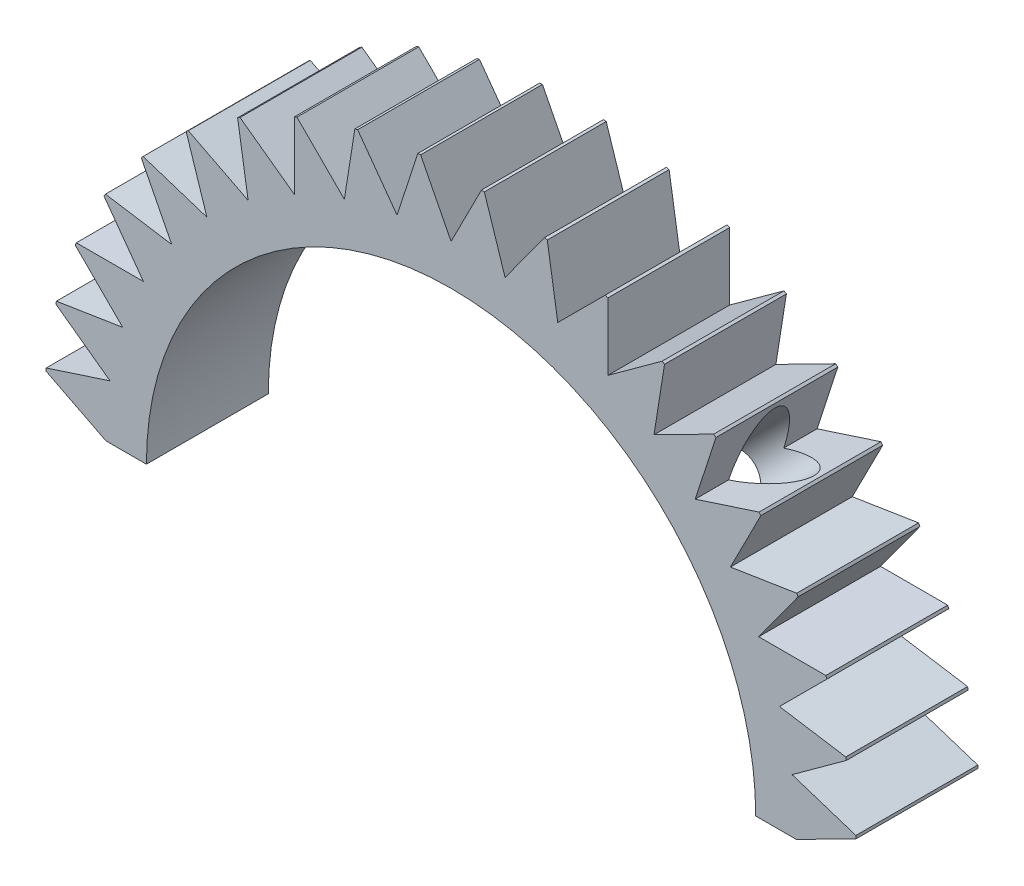
from build123d import *

# Parameters (mm, degrees)
BOSS_EXTRUDE1_DEPTH    = 7.5
CUT_EXTRUDE1_DEPTH     = 7.5
M8X1_25_TAPPED_HOLE4_D = 6.8
M8X1_25_TAPPED_HOLE5_D = 6.8


with BuildPart() as part:
    # Sketch1 → Boss-Extrude1 (new body, symmetric)
    with BuildSketch(Plane.XY):
        with BuildLine():
            Line((-50, 0), (-37.5, 0))
            ThreePointArc((-37.5, 0), (0, 37.5), (37.5, 0))
            Line((37.5, 0), (50, 0))
            ThreePointArc((50, 0), (0, 50), (-50, 0))
        make_face()
    extrude(amount=BOSS_EXTRUDE1_DEPTH, both=True)

    # Sketch2 → Cut-Extrude1 (cut, symmetric)
    with BuildSketch(Plane.XY):
        with BuildLine():
            Line((-3.75, 49.859176688), (0, 42.5))
            Line((0, 42.5), (3.75, 49.859176688))
            ThreePointArc((3.75, 49.859176688), (0, 50), (-3.75, 49.859176688))
        make_face()
        with BuildLine():
            Line((4.095862355, 49.83195673), (6.648464764, 41.976754475))
            Line((6.648464764, 41.976754475), (11.50352491, 48.658698242))
            ThreePointArc((11.50352491, 48.658698242), (7.821723252, 49.38441703), (4.095862355, 49.83195673))
        make_face()
        with BuildLine():
            Line((11.840870986, 48.577708615), (13.133222261, 40.419901943))
            Line((13.133222261, 40.419901943), (18.973794858, 46.260081157))
            ThreePointArc((18.973794858, 46.260081157), (15.450849719, 47.552825815), (11.840870986, 48.577708615))
        make_face()
        with BuildLine():
            Line((19.294318075, 46.127316094), (19.294596239, 37.867777278))
            Line((19.294596239, 37.867777278), (25.976867007, 42.722387346))
            ThreePointArc((25.976867007, 42.722387346), (22.699524987, 44.550326209), (19.294318075, 46.127316094))
        make_face()
        with BuildLine():
            Line((26.27267502, 42.541115962), (24.980873222, 34.383222261))
            Line((24.980873222, 34.383222261), (32.340302478, 38.13272657))
            ThreePointArc((32.340302478, 38.13272657), (29.389262615, 40.450849719), (26.27267502, 42.541115962))
        make_face()
        with BuildLine():
            Line((32.604111511, 37.90741237), (30.0520382, 30.0520382))
            Line((30.0520382, 30.0520382), (37.90741237, 32.604111511))
            ThreePointArc((37.90741237, 32.604111511), (35.355339059, 35.355339059), (32.604111511, 37.90741237))
        make_face()
        with BuildLine():
            Line((38.13272657, 32.340302478), (34.383222261, 24.980873222))
            Line((34.383222261, 24.980873222), (42.541115962, 26.27267502))
            ThreePointArc((42.541115962, 26.27267502), (40.450849719, 29.389262615), (38.13272657, 32.340302478))
        make_face()
        with BuildLine():
            Line((42.722387346, 25.976867007), (37.867777278, 19.294596239))
            Line((37.867777278, 19.294596239), (46.127316094, 19.294318075))
            ThreePointArc((46.127316094, 19.294318075), (44.550326209, 22.699524987), (42.722387346, 25.976867007))
        make_face()
        with BuildLine():
            Line((46.260081157, 18.973794858), (40.419901943, 13.133222261))
            Line((40.419901943, 13.133222261), (48.577708615, 11.840870986))
            ThreePointArc((48.577708615, 11.840870986), (47.552825815, 15.450849719), (46.260081157, 18.973794858))
        make_face()
        with BuildLine():
            Line((48.658698242, 11.50352491), (41.976754475, 6.648464764))
            Line((41.976754475, 6.648464764), (49.83195673, 4.095862355))
            ThreePointArc((49.83195673, 4.095862355), (49.38441703, 7.821723252), (48.658698242, 11.50352491))
        make_face()
        with BuildLine():
            Line((49.859176688, 3.75), (42.5, 0))
            Line((42.5, 0), (49.859176688, -3.75))
            ThreePointArc((49.859176688, -3.75), (50, 0), (49.859176688, 3.75))
        make_face()
        with BuildLine():
            Line((-49.859176688, -3.75), (-42.5, 0))
            Line((-42.5, 0), (-49.859176688, 3.75))
            ThreePointArc((-49.859176688, 3.75), (-50, 0), (-49.859176688, -3.75))
        make_face()
        with BuildLine():
            Line((-49.83195673, 4.095862355), (-41.976754475, 6.648464764))
            Line((-41.976754475, 6.648464764), (-48.658698242, 11.50352491))
            ThreePointArc((-48.658698242, 11.50352491), (-49.38441703, 7.821723252), (-49.83195673, 4.095862355))
        make_face()
        with BuildLine():
            Line((-48.577708615, 11.840870986), (-40.419901943, 13.133222261))
            Line((-40.419901943, 13.133222261), (-46.260081157, 18.973794858))
            ThreePointArc((-46.260081157, 18.973794858), (-47.552825815, 15.450849719), (-48.577708615, 11.840870986))
        make_face()
        with BuildLine():
            Line((-46.127316094, 19.294318075), (-37.867777278, 19.294596239))
            Line((-37.867777278, 19.294596239), (-42.722387346, 25.976867007))
            ThreePointArc((-42.722387346, 25.976867007), (-44.550326209, 22.699524987), (-46.127316094, 19.294318075))
        make_face()
        with BuildLine():
            Line((-42.541115962, 26.27267502), (-34.383222261, 24.980873222))
            Line((-34.383222261, 24.980873222), (-38.13272657, 32.340302478))
            ThreePointArc((-38.13272657, 32.340302478), (-40.450849719, 29.389262615), (-42.541115962, 26.27267502))
        make_face()
        with BuildLine():
            Line((-37.90741237, 32.604111511), (-30.0520382, 30.0520382))
            Line((-30.0520382, 30.0520382), (-32.604111511, 37.90741237))
            ThreePointArc((-32.604111511, 37.90741237), (-35.355339059, 35.355339059), (-37.90741237, 32.604111511))
        make_face()
        with BuildLine():
            Line((-32.340302478, 38.13272657), (-24.980873222, 34.383222261))
            Line((-24.980873222, 34.383222261), (-26.27267502, 42.541115962))
            ThreePointArc((-26.27267502, 42.541115962), (-29.389262615, 40.450849719), (-32.340302478, 38.13272657))
        make_face()
        with BuildLine():
            Line((-25.976867007, 42.722387346), (-19.294596239, 37.867777278))
            Line((-19.294596239, 37.867777278), (-19.294318075, 46.127316094))
            ThreePointArc((-19.294318075, 46.127316094), (-22.699524987, 44.550326209), (-25.976867007, 42.722387346))
        make_face()
        with BuildLine():
            Line((-18.973794858, 46.260081157), (-13.133222261, 40.419901943))
            Line((-13.133222261, 40.419901943), (-11.840870986, 48.577708615))
            ThreePointArc((-11.840870986, 48.577708615), (-15.450849719, 47.552825815), (-18.973794858, 46.260081157))
        make_face()
        with BuildLine():
            Line((-11.50352491, 48.658698242), (-6.648464764, 41.976754475))
            Line((-6.648464764, 41.976754475), (-4.095862355, 49.83195673))
            ThreePointArc((-4.095862355, 49.83195673), (-7.821723252, 49.38441703), (-11.50352491, 48.658698242))
        make_face()
    extrude(amount=CUT_EXTRUDE1_DEPTH, both=True, mode=Mode.SUBTRACT)

    # M8x1.25 Tapped Hole4 (through all)
    with Locations(Plane(origin=(-19.445436483, 19.445436483, 0), x_dir=(0, 0, -1), z_dir=(0.707106781, -0.707106781, 0))):
        with Locations((0, 0)):
            Hole(M8X1_25_TAPPED_HOLE4_D / 2)

    # M8x1.25 Tapped Hole5 (through all)
    with Locations(Plane(origin=(19.445436483, 19.445436483, 0), x_dir=(0, 0, -1), z_dir=(-0.707106781, -0.707106781, 0))):
        with Locations((0, 0)):
            Hole(M8X1_25_TAPPED_HOLE5_D / 2)


solid = part.part
